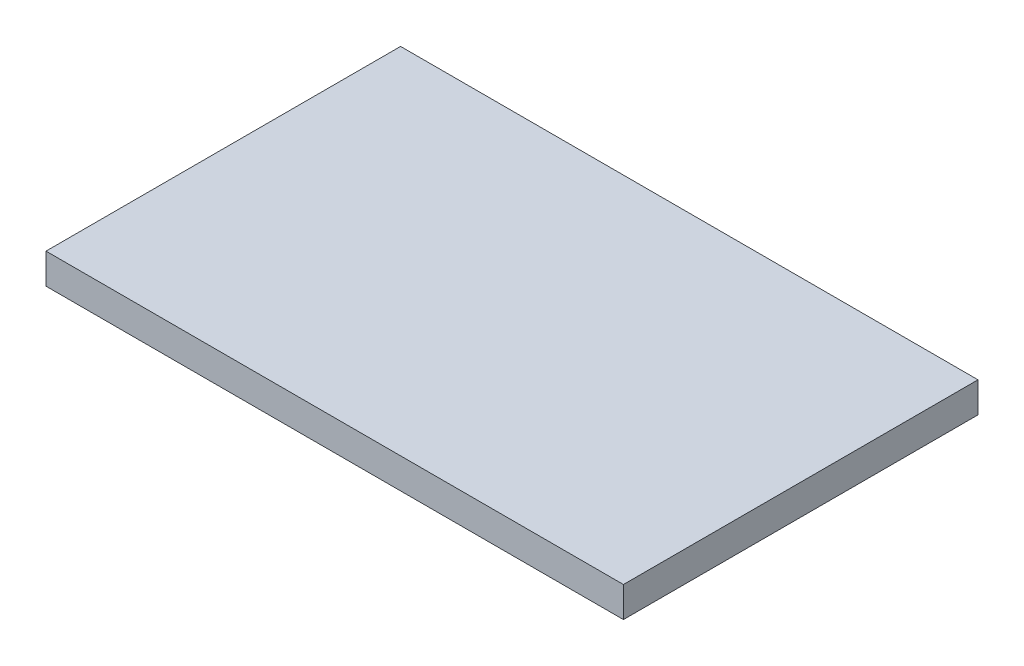
from build123d import *

# Parameters (mm, degrees)
SKETCH_1_W      = 570
SKETCH_1_H      = 350
EXTRUDE_1_DEPTH = 30


with BuildPart() as part:
    # Эскиз1 → Бобышка-Вытянуть1 (new body)
    with BuildSketch(Plane(origin=(0, 0, 0), x_dir=(1, 0, 0), z_dir=(0, 1, 0))):
        with Locations((285, 175)):
            Rectangle(SKETCH_1_W, SKETCH_1_H)
    extrude(amount=EXTRUDE_1_DEPTH)


solid = part.part
